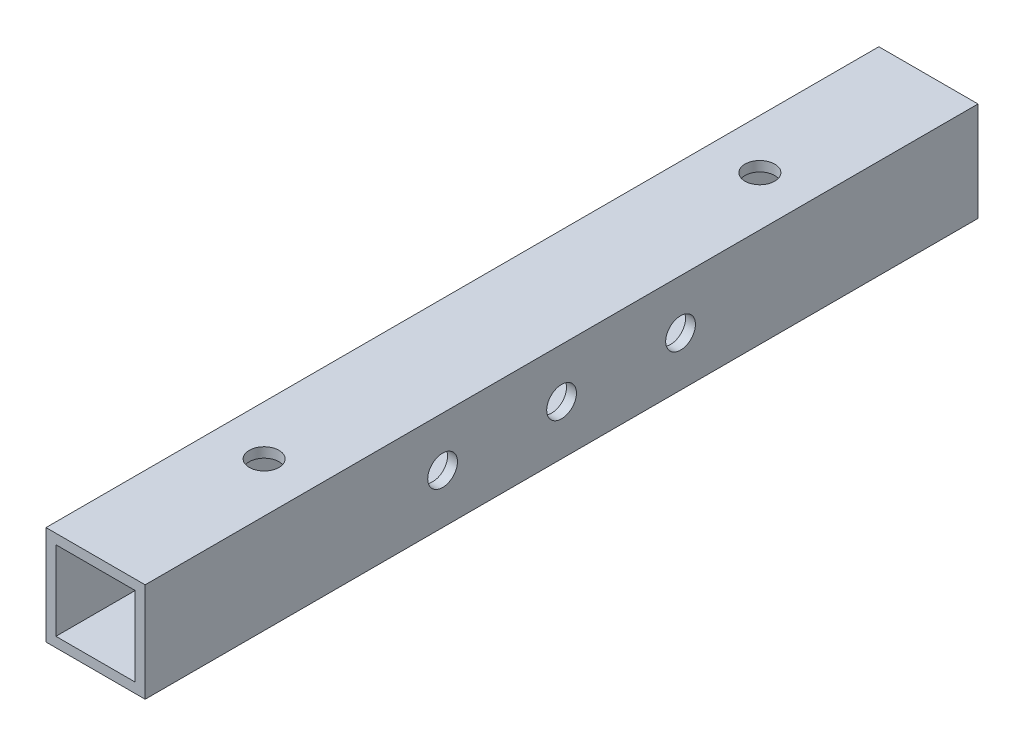
from build123d import *

# Parameters (mm, degrees)
SKETCH_1_W          = 10
SKETCH_1_H          = 10
SKETCH_1_W_2        = 8
SKETCH_1_H_2        = 8
EXTRUDE_1_DEPTH     = 84
SKETCH_2_R          = 1.5
CUT_EXTRUDE_1_DEPTH = 11
SKETCH_3_R          = 1.5
CUT_EXTRUDE_2_DEPTH = 11


with BuildPart() as part:
    # 草图1 → 拉伸-薄壁1 (new body)
    with BuildSketch(Plane.XY):
        Rectangle(SKETCH_1_W, SKETCH_1_H)
        Rectangle(SKETCH_1_W_2, SKETCH_1_H_2, mode=Mode.SUBTRACT)
    extrude(amount=EXTRUDE_1_DEPTH)

    # 草图2 → 切除-拉伸1 (cut, through all)
    with BuildSketch(Plane(origin=(5, 0, 0), x_dir=(0, 0, -1), z_dir=(1, 0, 0))):
        with Locations((-54, 0)):
            Circle(SKETCH_2_R)
        with Locations((-30, 0)):
            Circle(SKETCH_2_R)
        with Locations((-42, 0)):
            Circle(SKETCH_2_R)
    extrude(amount=-CUT_EXTRUDE_1_DEPTH, mode=Mode.SUBTRACT)

    # 草图3 → 切除-拉伸2 (cut, through all)
    with BuildSketch(Plane.XZ.offset(5)):
        with Locations((0, 17)):
            Circle(SKETCH_3_R)
        with Locations((0, 67)):
            Circle(SKETCH_3_R)
    extrude(amount=-CUT_EXTRUDE_2_DEPTH, mode=Mode.SUBTRACT)


solid = part.part
